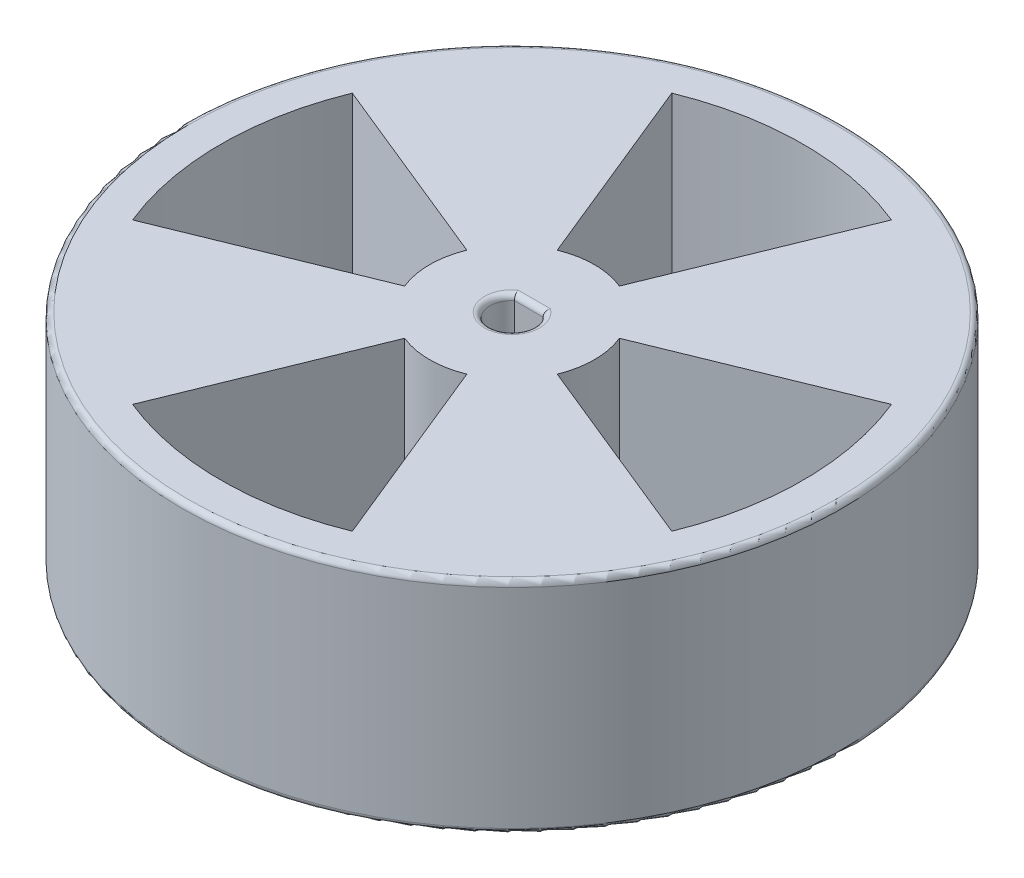
from build123d import *

# Parameters (mm, degrees)
SKETCH1_R           = 30
BOSS_EXTRUDE1_DEPTH = 20
FILLET1_R           = 0.5
CUT_EXTRUDE1_DEPTH  = 20


with BuildPart() as part:
    # Sketch1 → Boss-Extrude1 (new body)
    with BuildSketch(Plane(origin=(0, 0, 0), x_dir=(1, 0, 0), z_dir=(0, 1, 0))):
        Circle(SKETCH1_R)
        with BuildLine():
            Line((-1.3, 1.519868415), (1.3, 1.519868415))
            ThreePointArc((1.3, 1.519868415), (0, -2), (-1.3, 1.519868415))
        make_face(mode=Mode.SUBTRACT)
    extrude(amount=BOSS_EXTRUDE1_DEPTH)

    # Fillet1
    fillet1_edges = [part.edges().sort_by_distance(p)[0] for p in [
        (0, 20, -1.519868415),
        (-30, 20, 0),
        (-30, 0, 0),
        (0, 0, -1.519868415),
        (0, 0, 2),
        (0, 20, 2),
    ]]
    fillet(fillet1_edges, radius=FILLET1_R)

    # Sketch3 → Cut-Extrude1 (cut)
    with BuildSketch(Plane(origin=(0, 20, 0), x_dir=(1, 0, 0), z_dir=(0, 1, 0))):
        with BuildLine():
            ThreePointArc((10, 24.540782384), (0, 26.5), (-10, 24.540782384))
            Line((-10, 24.540782384), (-2.830188679, 6.945504448))
            ThreePointArc((-2.830188679, 6.945504448), (0, 7.5), (2.830188679, 6.945504448))
            Line((2.830188679, 6.945504448), (10, 24.540782384))
        make_face()
        with BuildLine():
            Line((-6.945504448, 2.830188679), (-24.540782384, 10))
            ThreePointArc((-24.540782384, 10), (-26.5, 0), (-24.540782384, -10))
            Line((-24.540782384, -10), (-6.945504448, -2.830188679))
            ThreePointArc((-6.945504448, -2.830188679), (-7.5, 0), (-6.945504448, 2.830188679))
        make_face()
        with BuildLine():
            ThreePointArc((26.5, 0), (26.005583373, 5.095059707), (24.540782384, 10))
            Line((24.540782384, 10), (6.945504448, 2.830188679))
            ThreePointArc((6.945504448, 2.830188679), (7.360070766, 1.44199803), (7.5, 0))
            ThreePointArc((7.5, 0), (7.360070766, -1.44199803), (6.945504448, -2.830188679))
            Line((6.945504448, -2.830188679), (24.540782384, -10))
            ThreePointArc((24.540782384, -10), (26.005583373, -5.095059707), (26.5, 0))
        make_face()
        with BuildLine():
            Line((-2.830188679, -6.945504448), (-10, -24.540782384))
            ThreePointArc((-10, -24.540782384), (0, -26.5), (10, -24.540782384))
            Line((10, -24.540782384), (2.830188679, -6.945504448))
            ThreePointArc((2.830188679, -6.945504448), (0, -7.5), (-2.830188679, -6.945504448))
        make_face()
    extrude(amount=-CUT_EXTRUDE1_DEPTH, mode=Mode.SUBTRACT)


solid = part.part
